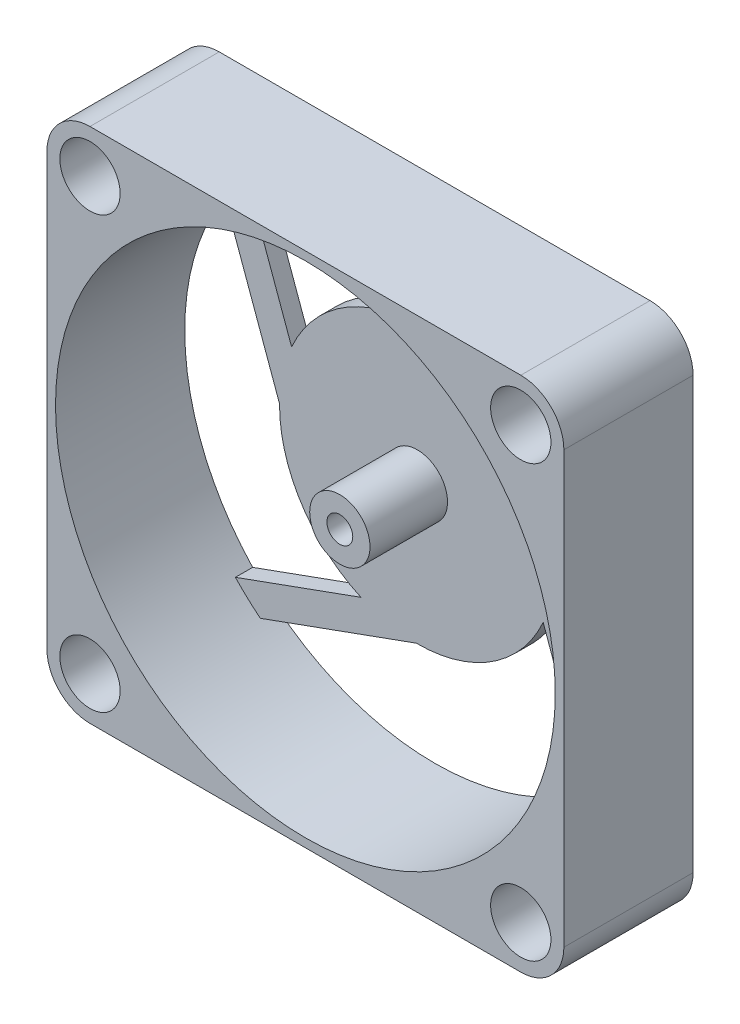
from build123d import *

# Parameters (mm, degrees)
ESBO_O1_W                = 60
ESBO_O1_H                = 60
ESBO_O1_R                = 29
RESSALTO_EXTRUS_O1_DEPTH = 15
ESBO_O2_R                = 2
CORTE_EXTRUS_O1_DEPTH    = 15
ESBO_O3_R                = 3.5
CORTE_EXTRUS_O2_DEPTH    = 5
FILETE1_R                = 5
RESSALTO_EXTRUS_O2_DEPTH = 2
ESBO_O5_R                = 3.5
RESSALTO_EXTRUS_O3_DEPTH = 9
ESBO_O6_R                = 1.5
CORTE_EXTRUS_O3_DEPTH    = 18.3
ESBO_O7_R                = 2.5
CORTE_EXTRUS_O4_DEPTH    = 1.5


with BuildPart() as part:
    # Esboço1 → Ressalto-extrusão1 (new body)
    with BuildSketch(Plane.XY):
        with Locations((30, 30)):
            Rectangle(ESBO_O1_W, ESBO_O1_H)
        with Locations((30, 30)):
            Circle(ESBO_O1_R, mode=Mode.SUBTRACT)
    extrude(amount=RESSALTO_EXTRUS_O1_DEPTH)

    # Esboço2 → Corte-extrusão1 (cut)
    with BuildSketch(Plane.XY.offset(15)):
        with Locations((5, 55)):
            Circle(ESBO_O2_R)
        with Locations((55, 55)):
            Circle(ESBO_O2_R)
        with Locations((55, 5)):
            Circle(ESBO_O2_R)
        with Locations((5, 5)):
            Circle(ESBO_O2_R)
    extrude(amount=-CORTE_EXTRUS_O1_DEPTH, mode=Mode.SUBTRACT)

    # Esboço3 → Corte-extrusão2 (cut)
    with BuildSketch(Plane.XY.offset(15)):
        with Locations((5, 55)):
            Circle(ESBO_O3_R)
        with Locations((55, 55)):
            Circle(ESBO_O3_R)
        with Locations((55, 5)):
            Circle(ESBO_O3_R)
        with Locations((5, 5)):
            Circle(ESBO_O3_R)
    extrude(amount=-CORTE_EXTRUS_O2_DEPTH, mode=Mode.SUBTRACT)

    # Filete1
    filete1_edges = [part.edges().sort_by_distance(p)[0] for p in [
        (0, 60, 7.5),
        (60, 60, 7.5),
        (60, 0, 7.5),
        (0, 0, 7.5),
    ]]
    fillet(filete1_edges, radius=FILETE1_R)

    # Esboço4 → Ressalto-extrusão2 (add)
    with BuildSketch(Plane(origin=(0, 0, 0), x_dir=(-1, 0, 0), z_dir=(0, 0, -1))):
        with BuildLine():
            Line((-30.130751647, 45.999465741), (-48.233254252, 52.551018589))
            ThreePointArc((-48.233254252, 52.551018589), (-49.721988735, 51.261306647), (-51.119742067, 49.873512398))
            Line((-51.119742067, 49.873512398), (-36.546722488, 44.599329596))
            ThreePointArc((-36.546722488, 44.599329596), (-43.465751902, 38.641384479), (-45.999465741, 29.869248353))
            Line((-45.999465741, 29.869248353), (-52.551018589, 11.766745748))
            ThreePointArc((-52.551018589, 11.766745748), (-51.261306647, 10.278011265), (-49.873512398, 8.880257933))
            Line((-49.873512398, 8.880257933), (-44.599329596, 23.453277512))
            ThreePointArc((-44.599329596, 23.453277512), (-38.641384479, 16.534248098), (-29.869248353, 14.000534259))
            Line((-29.869248353, 14.000534259), (-11.766745748, 7.448981411))
            ThreePointArc((-11.766745748, 7.448981411), (-10.278011265, 8.738693353), (-8.880257933, 10.126487602))
            Line((-8.880257933, 10.126487602), (-23.453277512, 15.400670404))
            ThreePointArc((-23.453277512, 15.400670404), (-16.534248098, 21.358615521), (-14.000534259, 30.130751647))
            Line((-14.000534259, 30.130751647), (-7.448981411, 48.233254252))
            ThreePointArc((-7.448981411, 48.233254252), (-8.738693353, 49.721988735), (-10.126487602, 51.119742067))
            Line((-10.126487602, 51.119742067), (-15.400670404, 36.546722488))
            ThreePointArc((-15.400670404, 36.546722488), (-21.358615521, 43.465751902), (-30.130751647, 45.999465741))
        make_face()
    extrude(amount=-RESSALTO_EXTRUS_O2_DEPTH)

    # Esboço5 → Ressalto-extrusão3 (add)
    with BuildSketch(Plane.XY.offset(2)):
        with Locations((30, 30)):
            Circle(ESBO_O5_R)
    extrude(amount=RESSALTO_EXTRUS_O3_DEPTH)

    # Esboço6 → Corte-extrusão3 (cut)
    with BuildSketch(Plane.XY.offset(11)):
        with Locations((30, 30)):
            Circle(ESBO_O6_R)
    extrude(amount=-CORTE_EXTRUS_O3_DEPTH, mode=Mode.SUBTRACT)

    # Esboço7 → Corte-extrusão4 (cut)
    with BuildSketch(Plane(origin=(0, 0, 0), x_dir=(-1, 0, 0), z_dir=(0, 0, -1))):
        with Locations((-30, 30)):
            Circle(ESBO_O7_R)
    extrude(amount=-CORTE_EXTRUS_O4_DEPTH, mode=Mode.SUBTRACT)


solid = part.part
